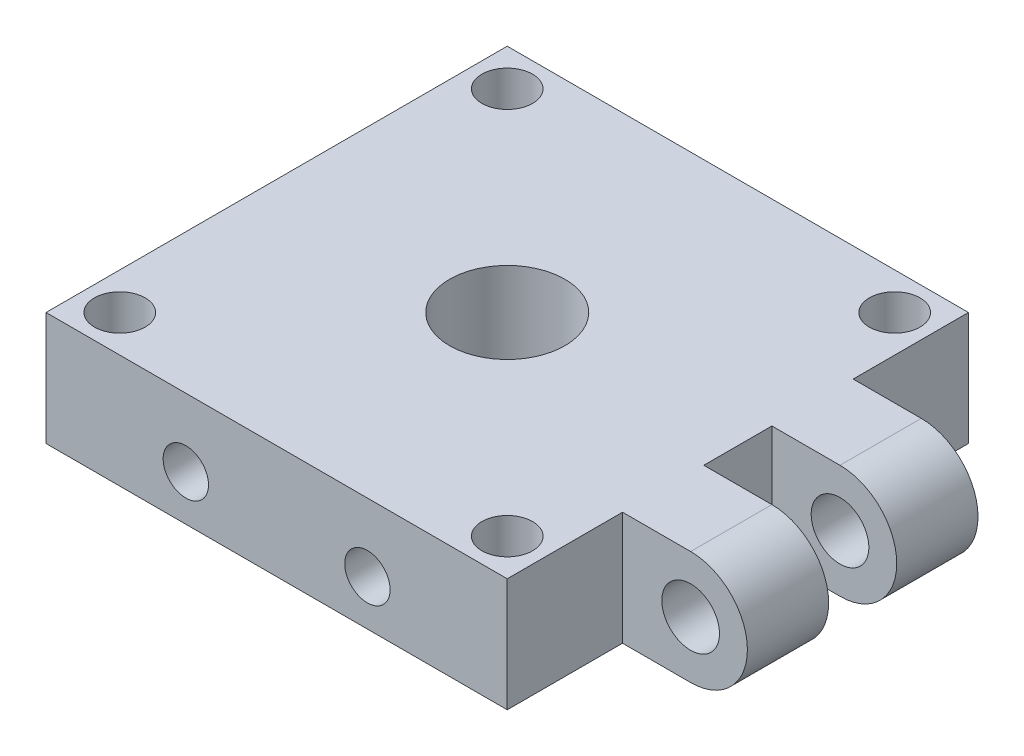
from build123d import *

# Parameters (mm, degrees)
SKETCH1_W           = 50.8
SKETCH1_H           = 50.8
SKETCH1_R           = 2.794
SKETCH1_R_2         = 6.35
BOSS_EXTRUDE1_DEPTH = 12.5
SKETCH4_R           = 3.175
BOSS_EXTRUDE2_DEPTH = 12.7
SKETCH5_W           = 13.75
SKETCH5_H           = 7.5
CUT_EXTRUDE2_DEPTH  = 13.5
SKETCH14_R          = 2.5
CUT_EXTRUDE7_DEPTH  = 20
SKETCH15_R          = 2.5
CUT_EXTRUDE8_DEPTH  = 20


with BuildPart() as part:
    # Sketch1 → Boss-Extrude1 (new body)
    with BuildSketch(Plane(origin=(0, 0, 0), x_dir=(1, 0, 0), z_dir=(0, 1, 0))):
        Rectangle(SKETCH1_W, SKETCH1_H)
        with Locations((-21.336, -21.336)):
            Circle(SKETCH1_R, mode=Mode.SUBTRACT)
        with Locations((21.336, -21.336)):
            Circle(SKETCH1_R, mode=Mode.SUBTRACT)
        with Locations((21.336, 21.336)):
            Circle(SKETCH1_R, mode=Mode.SUBTRACT)
        with Locations((-21.336, 21.336)):
            Circle(SKETCH1_R, mode=Mode.SUBTRACT)
        Circle(SKETCH1_R_2, mode=Mode.SUBTRACT)
    extrude(amount=BOSS_EXTRUDE1_DEPTH)

    # Sketch4 → Boss-Extrude2 (add, symmetric)
    with BuildSketch(Plane.XY):
        with BuildLine():
            Line((25.4, 0), (32.9, 0))
            ThreePointArc((32.9, 0), (39.15, 6.25), (32.9, 12.5))
            Line((32.9, 12.5), (25.4, 12.5))
            Line((25.4, 12.5), (25.4, 0))
        make_face()
        with Locations((32.9, 6.25)):
            Circle(SKETCH4_R, mode=Mode.SUBTRACT)
    extrude(amount=BOSS_EXTRUDE2_DEPTH, both=True)

    # Sketch5 → Cut-Extrude2 (cut, through all)
    with BuildSketch(Plane(origin=(0, 12.5, 0), x_dir=(1, 0, 0), z_dir=(0, 1, 0))):
        with Locations((32.275, 0)):
            Rectangle(SKETCH5_W, SKETCH5_H)
    extrude(amount=-CUT_EXTRUDE2_DEPTH, mode=Mode.SUBTRACT)

    # Sketch14 → Cut-Extrude7 (cut)
    with BuildSketch(Plane.XY.offset(25.4)):
        with Locations((-10, 5)):
            Circle(SKETCH14_R)
        with Locations((10, 5)):
            Circle(SKETCH14_R)
    extrude(amount=-CUT_EXTRUDE7_DEPTH, mode=Mode.SUBTRACT)

    # Sketch15 → Cut-Extrude8 (cut)
    with BuildSketch(Plane.ZY.offset(25.4)):
        with Locations((-10, 5)):
            Circle(SKETCH15_R)
        with Locations((10, 5)):
            Circle(SKETCH15_R)
    extrude(amount=-CUT_EXTRUDE8_DEPTH, mode=Mode.SUBTRACT)


solid = part.part
